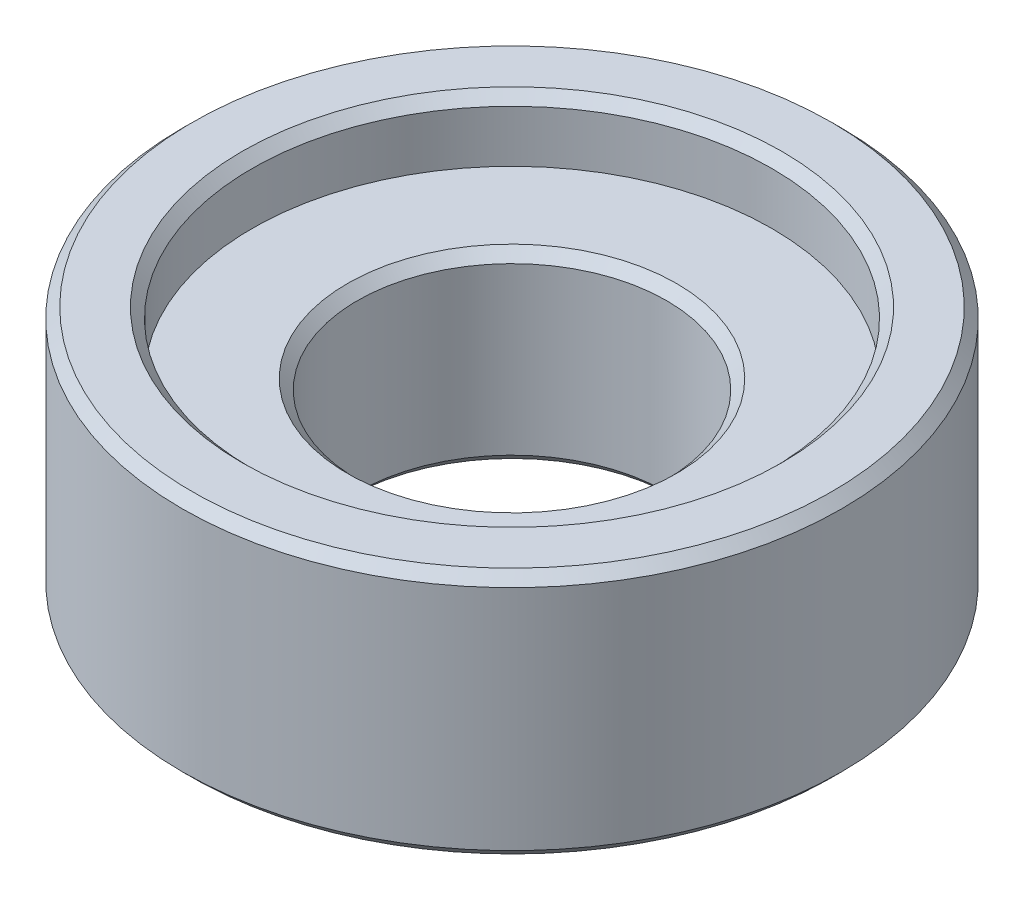
from build123d import *


with BuildPart() as part:
    # Sketch1 → Revolve1 (revolve)
    with BuildSketch(Plane.XY):
        Polygon((16.4084, 12.7), (13.843, 12.7), (13.335, 12.192), (13.335, 9.525), (8.4455, 9.525), (7.9375, 9.017), (7.9375, 0.508), (8.4455, 0), (16.4084, 0), (16.9164, 0.508), (16.9164, 12.192), align=None)
    revolve(axis=Axis((0, 12.7, 0), (0, -1, 0)))


solid = part.part
